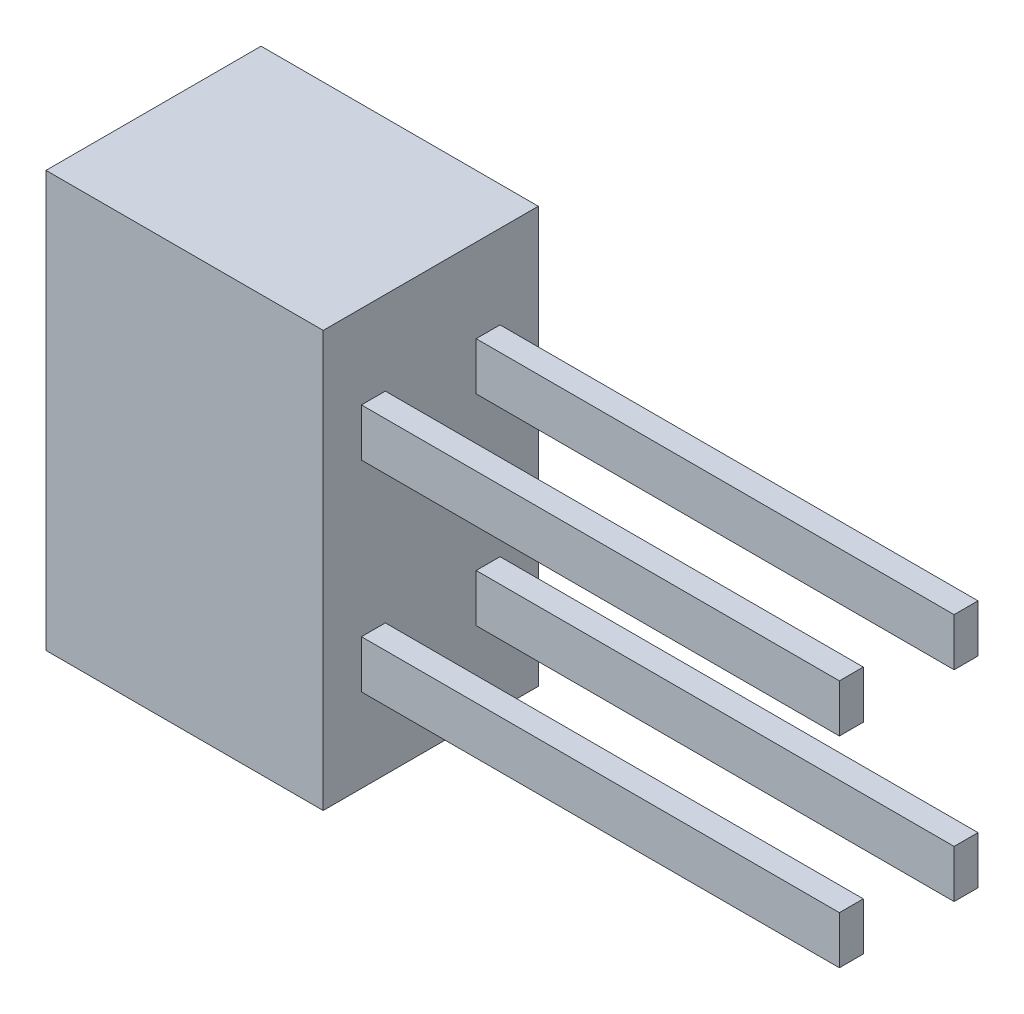
from build123d import *

# Parameters (mm, degrees)
SKETCH1_W           = 4.5
SKETCH1_H           = 8.7
BOSS_EXTRUDE1_DEPTH = 5.8
SKETCH2_W           = 0.5
SKETCH2_H           = 1
BOSS_EXTRUDE2_DEPTH = 10


with BuildPart() as part:
    # Sketch1 → Boss-Extrude1 (new body)
    with BuildSketch(Plane(origin=(0, 0, 0), x_dir=(0, 0, -1), z_dir=(1, 0, 0))):
        Rectangle(SKETCH1_W, SKETCH1_H)
    extrude(amount=BOSS_EXTRUDE1_DEPTH)

    # Sketch2 → Boss-Extrude2 (add)
    with BuildSketch(Plane(origin=(5.8, 0, 0), x_dir=(0, 0, -1), z_dir=(1, 0, 0))):
        with Locations((-1.2, -2.1)):
            Rectangle(SKETCH2_W, SKETCH2_H)
        with Locations((-1.2, 2.1)):
            Rectangle(SKETCH2_W, SKETCH2_H)
        with Locations((1.2, 2.1)):
            Rectangle(SKETCH2_W, SKETCH2_H)
        with Locations((1.2, -2.1)):
            Rectangle(SKETCH2_W, SKETCH2_H)
    extrude(amount=BOSS_EXTRUDE2_DEPTH)


solid = part.part
